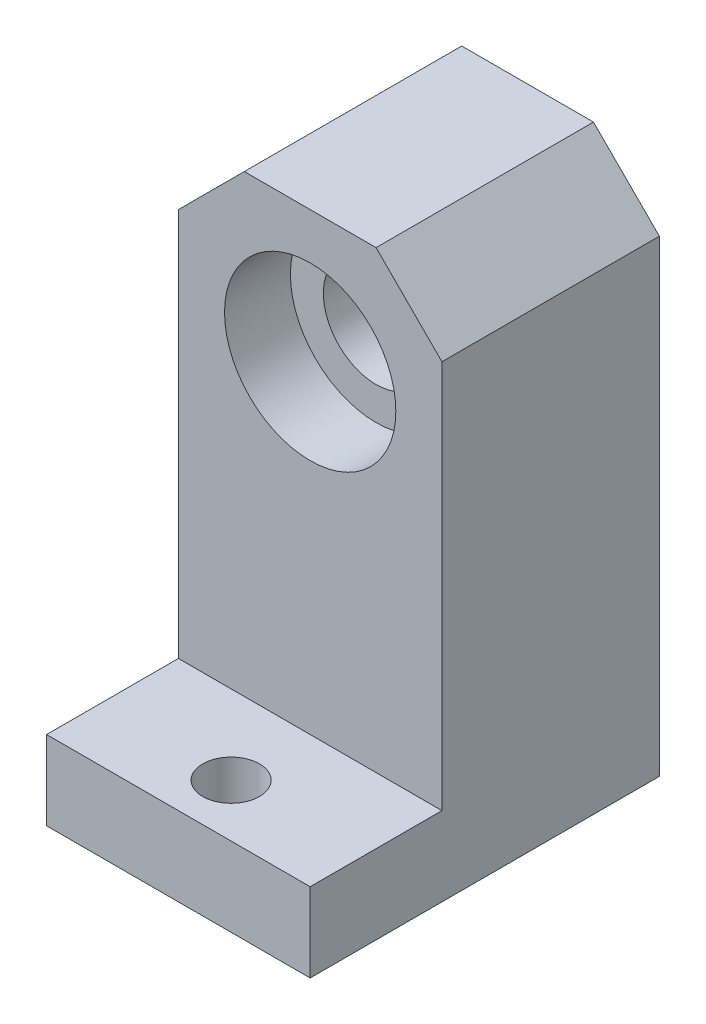
from build123d import *

# Parameters (mm, degrees)
SKETCH_1_W          = 20
SKETCH_1_H          = 40.5
EXTRUDE_1_DEPTH     = 8.25
SKETCH_2_R          = 4
CUT_EXTRUDE_1_DEPTH = 17.5
SKETCH_3_R          = 6.5
CUT_EXTRUDE_2_DEPTH = 5
CHAMFER_1_SIZE      = 5
SKETCH_4_W          = 10
SKETCH_4_H          = 6
EXTRUDE_2_DEPTH     = 20
SKETCH_5_R          = 2.15
CUT_EXTRUDE_3_DEPTH = 17


with BuildPart() as part:
    # 草图1 → 凸台-拉伸1 (new body, symmetric)
    with BuildSketch(Plane.XY):
        with Locations((0, 20.25)):
            Rectangle(SKETCH_1_W, SKETCH_1_H)
    extrude(amount=EXTRUDE_1_DEPTH, both=True)

    # 草图2 → 切除-拉伸1 (cut, through all)
    with BuildSketch(Plane.XY.offset(8.25)):
        with Locations((0, 30.5)):
            Circle(SKETCH_2_R)
    extrude(amount=-CUT_EXTRUDE_1_DEPTH, mode=Mode.SUBTRACT)

    # 草图3 → 切除-拉伸2 (cut)
    with BuildSketch(Plane.XY.offset(8.25)):
        with Locations((0, 30.5)):
            Circle(SKETCH_3_R)
    cut_extrude_2 = extrude(amount=-CUT_EXTRUDE_2_DEPTH, mode=Mode.SUBTRACT)

    # 镜向1: 切除-拉伸2 across plane
    add(cut_extrude_2.mirror(Plane.XY), mode=Mode.SUBTRACT)

    # 倒角1
    chamfer_1_edges = [part.edges().sort_by_distance(p)[0] for p in [
        (-10, 40.5, 0),
        (10, 40.5, 0),
    ]]
    chamfer(chamfer_1_edges, length=CHAMFER_1_SIZE)

    # 草图4 → 凸台-拉伸2 (add)
    with BuildSketch(Plane(origin=(10, 0, 0), x_dir=(0, 0, -1), z_dir=(1, 0, 0))):
        with Locations((-13.25, 3)):
            Rectangle(SKETCH_4_W, SKETCH_4_H)
    extrude(amount=-EXTRUDE_2_DEPTH)

    # 草图5 → 切除-拉伸3 (cut)
    with BuildSketch(Plane(origin=(0, 6, 0), x_dir=(1, 0, 0), z_dir=(0, 1, 0))):
        with Locations((0, -14.25)):
            Circle(SKETCH_5_R)
    extrude(amount=-CUT_EXTRUDE_3_DEPTH, mode=Mode.SUBTRACT)


solid = part.part
